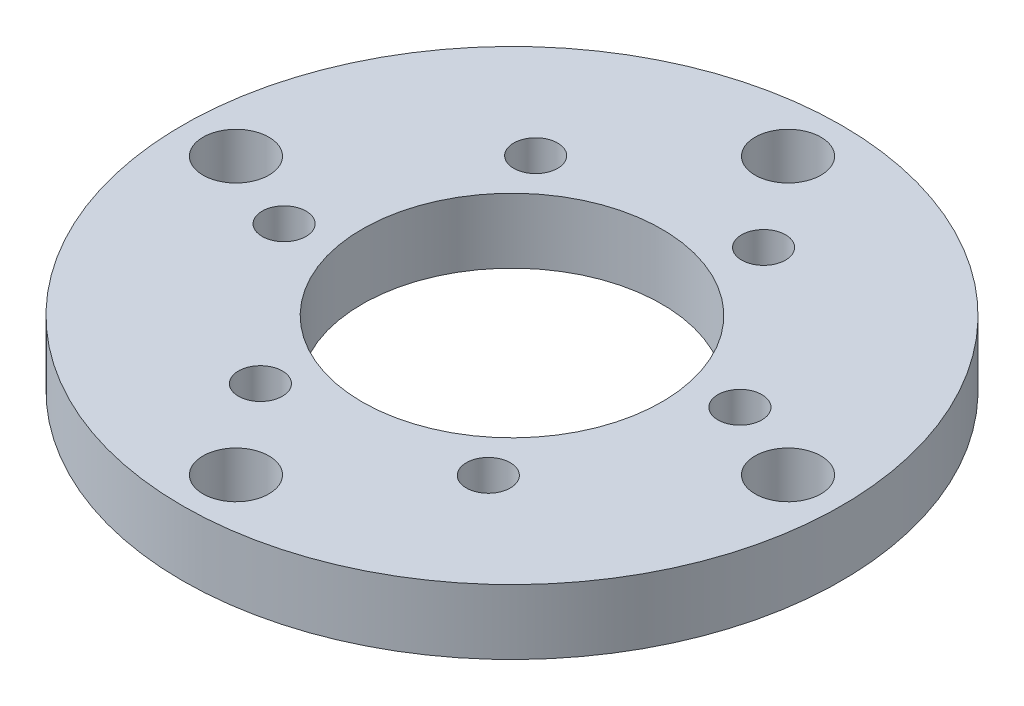
from build123d import *

# Parameters (mm, degrees)
SKETCH1_W           = 88.9
SKETCH1_H           = 88.9
BOSS_EXTRUDE1_DEPTH = 8.255
SKETCH5_W           = 88.9
SKETCH5_H           = 88.9
SKETCH5_R           = 41.91
CUT_EXTRUDE5_DEPTH  = 8.255
SKETCH9_R           = 4.191
CUT_EXTRUDE7_DEPTH  = 8.255
CIRPATTERN1_COUNT   = 4
CUT_EXTRUDE9_DEPTH  = 8.255
CIRPATTERN3_COUNT   = 6
SKETCH8_R           = 19.05
CUT_EXTRUDE10_DEPTH = 8.255


with BuildPart() as part:
    # Sketch1 → Boss-Extrude1 (new body)
    with BuildSketch(Plane(origin=(0, 0, 0), x_dir=(1, 0, 0), z_dir=(0, 1, 0))):
        with Locations((44.45, -44.45)):
            Rectangle(SKETCH1_W, SKETCH1_H)
    extrude(amount=-BOSS_EXTRUDE1_DEPTH)

    # Sketch5 → Cut-Extrude5 (cut)
    with BuildSketch(Plane(origin=(0, 0, 0), x_dir=(1, 0, 0), z_dir=(0, 1, 0))):
        with Locations((44.45, -44.45)):
            Rectangle(SKETCH5_W, SKETCH5_H)
        with Locations((44.45, -44.45)):
            Circle(SKETCH5_R, mode=Mode.SUBTRACT)
    extrude(amount=-CUT_EXTRUDE5_DEPTH, mode=Mode.SUBTRACT)

    # Sketch9 → Cut-Extrude7 (cut)
    with BuildSketch(Plane(origin=(0, 0, 0), x_dir=(1, 0, 0), z_dir=(0, 1, 0))):
        with Locations((44.45, -79.5528)):
            Circle(SKETCH9_R)
    cut_extrude7 = extrude(amount=-CUT_EXTRUDE7_DEPTH, mode=Mode.SUBTRACT)

    # CirPattern1: Cut-Extrude7 ×4 about axis
    cirpattern1_axis = Axis((44.45, 0, 44.45), (0, 1, 0))
    for i in range(1, CIRPATTERN1_COUNT):
        add(cut_extrude7.rotate(cirpattern1_axis, i * 360 / CIRPATTERN1_COUNT), mode=Mode.SUBTRACT)

    # Sketch11 → Cut-Extrude9 (cut)
    with BuildSketch(Plane(origin=(0, 0, 0), x_dir=(1, 0, 0), z_dir=(0, 1, 0))):
        with BuildLine():
            ThreePointArc((38.743889634, -67.945), (38.237051273, -66.340217261), (36.900419598, -65.317657467))
            Line((36.900419598, -65.317657467), (34.99935967, -70.572342533))
            ThreePointArc((34.99935967, -70.572342533), (37.554672374, -70.232161638), (38.743889634, -67.945))
        make_face()
        with BuildLine():
            Line((34.99935967, -70.572342533), (36.900419598, -65.317657467))
            ThreePointArc((36.900419598, -65.317657467), (33.322547101, -66.994470036), (34.99935967, -70.572342533))
        make_face()
    cut_extrude9 = extrude(amount=-CUT_EXTRUDE9_DEPTH, mode=Mode.SUBTRACT)

    # CirPattern3: Cut-Extrude9 ×6 about axis
    cirpattern3_axis = Axis((44.45, 0, 44.45), (0, 1, 0))
    for i in range(1, CIRPATTERN3_COUNT):
        add(cut_extrude9.rotate(cirpattern3_axis, i * 360 / CIRPATTERN3_COUNT), mode=Mode.SUBTRACT)

    # Sketch8 → Cut-Extrude10 (cut)
    with BuildSketch(Plane(origin=(0, 0, 0), x_dir=(1, 0, 0), z_dir=(0, 1, 0))):
        with Locations((44.45, -44.45)):
            Circle(SKETCH8_R)
    extrude(amount=-CUT_EXTRUDE10_DEPTH, mode=Mode.SUBTRACT)


solid = part.part
